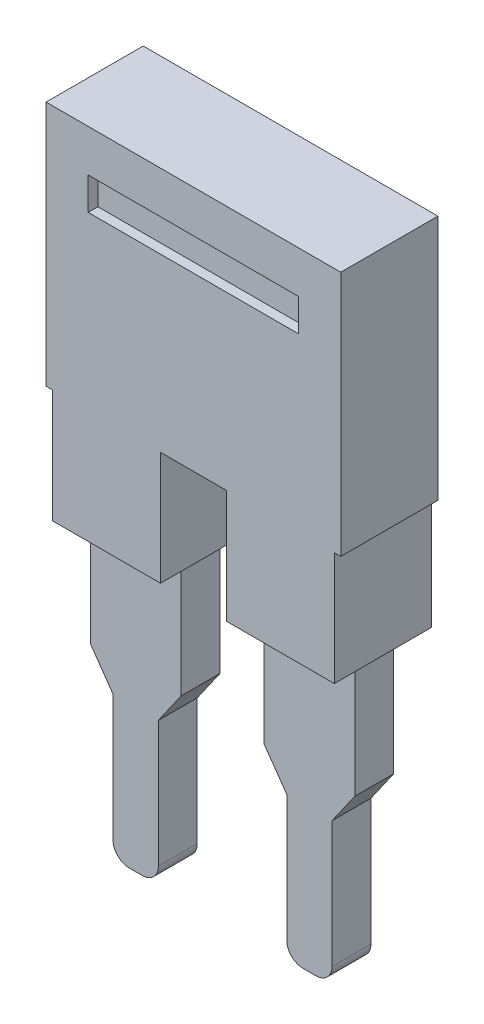
from build123d import *

# Parameters (mm, degrees)
PLASTIC_BODY_DEPTH   = 1.5
SKETCH2_W            = 6.5
SKETCH2_H            = 1
CUT_GRIP_DEPTH       = 0.3
BOSS_EXTRUDE2_DEPTH  = 0.6
FILLET1_R            = 0.5
FILLET1_OF_MIRROR4_R = 0.5


with BuildPart() as part:
    # Sketch1 → plastic body (new body, symmetric)
    with BuildSketch(Plane.XY):
        Polygon((0, 7.6), (4.55, 7.6), (4.55, 0), (4.35, 0), (4.35, -3.5), (1.015, -3.5), (1.015, 0), (0, 0), align=None)
    plastic_body = extrude(amount=PLASTIC_BODY_DEPTH, both=True)

    # Mirror1: plastic body across plane
    add(plastic_body.mirror(Plane(origin=(0, 0, 0), x_dir=(0, 0, 1), z_dir=(1, 0, 0))))

    # Sketch2 → cut grip (cut, symmetric)
    with BuildSketch(Plane.XY.offset(1.5)):
        with Locations((0, 5.8)):
            Rectangle(SKETCH2_W, SKETCH2_H)
    cut_grip = extrude(amount=CUT_GRIP_DEPTH, both=True, mode=Mode.SUBTRACT)

    # Mirror2: cut grip across plane
    add(cut_grip.mirror(Plane.XY), mode=Mode.SUBTRACT)


with BuildPart() as body_2:
    # Sketch4 → Boss-Extrude2 (new body, symmetric)
    with BuildSketch(Plane.XY):
        Polygon((1.2825, -3.5), (1.2825, -7.1), (1.9825, -8.1), (1.9825, -12.5), (3.3825, -12.5), (3.3825, -8.1), (4.0825, -7.1), (4.0825, -3.5), align=None)
    boss_extrude2 = extrude(amount=BOSS_EXTRUDE2_DEPTH, both=True)

    # Fillet1
    fillet1_edges = [body_2.edges().sort_by_distance(p)[0] for p in [
        (3.3825, -12.5, 0),
        (1.9825, -12.5, 0),
    ]]
    fillet(fillet1_edges, radius=FILLET1_R)


with BuildPart() as part_1:
    add(part.part)

    # Mirror4: Boss-Extrude2 across plane
    add(boss_extrude2.mirror(Plane(origin=(0, 0, 0), x_dir=(0, 0, 1), z_dir=(1, 0, 0))))

    # Fillet1 of Mirror4
    fillet1_of_mirror4_edges = [part_1.edges().sort_by_distance(p)[0] for p in [
        (-3.3825, -12.5, 0),
        (-1.9825, -12.5, 0),
    ]]
    fillet(fillet1_of_mirror4_edges, radius=FILLET1_OF_MIRROR4_R)


solid = Compound([body_2.part, part_1.part])
